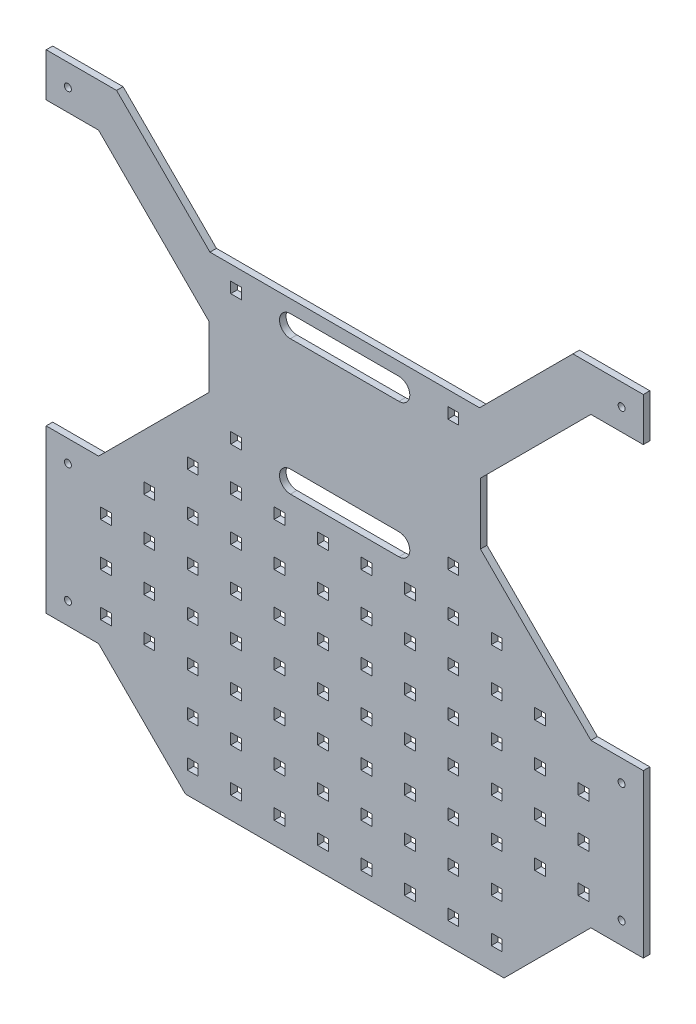
from build123d import *

# Parameters (mm, degrees)
EXTRUDE1_DEPTH     = 3
CUT_EXTRUDE2_DEPTH = 3
EXTRUDE3_DEPTH     = 10
SKETCH6_R          = 1.6
EXTRUDE4_DEPTH     = 50
SKETCH7_W          = 5
SKETCH7_H          = 5
EXTRUDE5_DEPTH     = 50


with BuildPart() as part:
    # Sketch1 → Extrude1 (new body)
    with BuildSketch(Plane.XY):
        Polygon((-21.510078765, 357.497048214), (2.632056859, 357.497048214), (53.489921235, 306.639183837), (53.489921235, 278.35491259), (2.632056859, 227.497048214), (-21.510078765, 227.497048214), (-21.510078765, 152.709593142), (2.632056859, 152.709593142), (42.632056859, 112.709593142), (189.347785611, 112.709593142), (229.347785611, 152.709593142), (253.489921235, 152.709593142), (253.489921235, 227.497048214), (229.347785611, 227.497048214), (178.489921235, 278.35491259), (178.489921235, 306.639183837), (229.347785611, 357.497048214), (253.489921235, 357.497048214), (253.489921235, 432.284503285), (185.989921235, 432.284503285), (165.989921235, 412.284503285), (65.989921235, 412.284503285), (45.989921235, 432.284503285), (-21.510078765, 432.284503285), align=None)
    extrude(amount=EXTRUDE1_DEPTH)

    # Sketch3 → Cut-Extrude2 (cut)
    with BuildSketch(Plane.XY.offset(3)):
        with BuildLine():
            Line((90.948770211, 328.497048214), (140.948770211, 328.497048214))
            ThreePointArc((140.948770211, 328.497048214), (145.948770211, 323.497048214), (140.948770211, 318.497048214))
            Line((140.948770211, 318.497048214), (90.948770211, 318.497048214))
            ThreePointArc((90.948770211, 318.497048214), (85.948770211, 323.497048214), (90.948770211, 328.497048214))
        make_face()
        with BuildLine():
            Line((90.948770211, 256.497048214), (140.948770211, 256.497048214))
            ThreePointArc((140.948770211, 256.497048214), (145.948770211, 261.497048214), (140.948770211, 266.497048214))
            Line((140.948770211, 266.497048214), (90.948770211, 266.497048214))
            ThreePointArc((90.948770211, 266.497048214), (85.948770211, 261.497048214), (90.948770211, 256.497048214))
        make_face()
    extrude(amount=-CUT_EXTRUDE2_DEPTH, mode=Mode.SUBTRACT)

    # Sketch5 → Extrude3 (cut)
    with BuildSketch(Plane(origin=(0, 0, 0), x_dir=(-1, 0, 0), z_dir=(0, 0, -1))):
        Polygon((-253.489921235, 377.497048214), (-221.063514364, 377.497048214), (-178.063514364, 334.497048214), (-53.916328106, 334.497048214), (-10.916328106, 377.497048214), (21.510078765, 377.497048214), (21.510078765, 432.284503285), (-253.489921235, 432.284503285), align=None)
    extrude(amount=-EXTRUDE3_DEPTH, mode=Mode.SUBTRACT)

    # Sketch6 → Extrude4 (cut)
    with BuildSketch(Plane.XY.offset(3)):
        with Locations((-11.510078765, 367.497048214)):
            Circle(SKETCH6_R)
        with Locations((-11.510078765, 217.497048214)):
            Circle(SKETCH6_R)
        with Locations((-11.510078765, 162.709593142)):
            Circle(SKETCH6_R)
        with Locations((243.489921235, 162.709593142)):
            Circle(SKETCH6_R)
        with Locations((243.489921235, 217.497048214)):
            Circle(SKETCH6_R)
        with Locations((243.489921235, 367.497048214)):
            Circle(SKETCH6_R)
    extrude(amount=-EXTRUDE4_DEPTH, mode=Mode.SUBTRACT)

    # Sketch7 → Extrude5 (cut)
    with BuildSketch(Plane.XY.offset(3)):
        with Locations((45.989921235, 125.209593142)):
            Rectangle(SKETCH7_W, SKETCH7_H)
        with Locations((65.989921235, 125.209593142)):
            Rectangle(SKETCH7_W, SKETCH7_H)
        with Locations((85.989921235, 125.209593142)):
            Rectangle(SKETCH7_W, SKETCH7_H)
        with Locations((105.989921235, 125.209593142)):
            Rectangle(SKETCH7_W, SKETCH7_H)
        with Locations((125.989921235, 125.209593142)):
            Rectangle(SKETCH7_W, SKETCH7_H)
        with Locations((145.989921235, 125.209593142)):
            Rectangle(SKETCH7_W, SKETCH7_H)
        with Locations((165.989921235, 125.209593142)):
            Rectangle(SKETCH7_W, SKETCH7_H)
        with Locations((185.989921235, 125.209593142)):
            Rectangle(SKETCH7_W, SKETCH7_H)
        with Locations((45.989921235, 145.209593142)):
            Rectangle(SKETCH7_W, SKETCH7_H)
        with Locations((65.989921235, 145.209593142)):
            Rectangle(SKETCH7_W, SKETCH7_H)
        with Locations((85.989921235, 145.209593142)):
            Rectangle(SKETCH7_W, SKETCH7_H)
        with Locations((105.989921235, 145.209593142)):
            Rectangle(SKETCH7_W, SKETCH7_H)
        with Locations((125.989921235, 145.209593142)):
            Rectangle(SKETCH7_W, SKETCH7_H)
        with Locations((145.989921235, 145.209593142)):
            Rectangle(SKETCH7_W, SKETCH7_H)
        with Locations((165.989921235, 145.209593142)):
            Rectangle(SKETCH7_W, SKETCH7_H)
        with Locations((185.989921235, 145.209593142)):
            Rectangle(SKETCH7_W, SKETCH7_H)
        with Locations((25.989921235, 165.209593142)):
            Rectangle(SKETCH7_W, SKETCH7_H)
        with Locations((45.989921235, 165.209593142)):
            Rectangle(SKETCH7_W, SKETCH7_H)
        with Locations((65.989921235, 165.209593142)):
            Rectangle(SKETCH7_W, SKETCH7_H)
        with Locations((85.989921235, 165.209593142)):
            Rectangle(SKETCH7_W, SKETCH7_H)
        with Locations((105.989921235, 165.209593142)):
            Rectangle(SKETCH7_W, SKETCH7_H)
        with Locations((125.989921235, 165.209593142)):
            Rectangle(SKETCH7_W, SKETCH7_H)
        with Locations((145.989921235, 165.209593142)):
            Rectangle(SKETCH7_W, SKETCH7_H)
        with Locations((165.989921235, 165.209593142)):
            Rectangle(SKETCH7_W, SKETCH7_H)
        with Locations((185.989921235, 165.209593142)):
            Rectangle(SKETCH7_W, SKETCH7_H)
        with Locations((205.989921235, 165.209593142)):
            Rectangle(SKETCH7_W, SKETCH7_H)
        with Locations((225.989921235, 165.209593142)):
            Rectangle(SKETCH7_W, SKETCH7_H)
        with Locations((25.989921235, 185.209593142)):
            Rectangle(SKETCH7_W, SKETCH7_H)
        with Locations((45.989921235, 185.209593142)):
            Rectangle(SKETCH7_W, SKETCH7_H)
        with Locations((65.989921235, 185.209593142)):
            Rectangle(SKETCH7_W, SKETCH7_H)
        with Locations((85.989921235, 185.209593142)):
            Rectangle(SKETCH7_W, SKETCH7_H)
        with Locations((105.989921235, 185.209593142)):
            Rectangle(SKETCH7_W, SKETCH7_H)
        with Locations((125.989921235, 185.209593142)):
            Rectangle(SKETCH7_W, SKETCH7_H)
        with Locations((145.989921235, 185.209593142)):
            Rectangle(SKETCH7_W, SKETCH7_H)
        with Locations((165.989921235, 185.209593142)):
            Rectangle(SKETCH7_W, SKETCH7_H)
        with Locations((185.989921235, 185.209593142)):
            Rectangle(SKETCH7_W, SKETCH7_H)
        with Locations((205.989921235, 185.209593142)):
            Rectangle(SKETCH7_W, SKETCH7_H)
        with Locations((225.989921235, 185.209593142)):
            Rectangle(SKETCH7_W, SKETCH7_H)
        with Locations((25.989921235, 205.209593142)):
            Rectangle(SKETCH7_W, SKETCH7_H)
        with Locations((45.989921235, 205.209593142)):
            Rectangle(SKETCH7_W, SKETCH7_H)
        with Locations((65.989921235, 205.209593142)):
            Rectangle(SKETCH7_W, SKETCH7_H)
        with Locations((85.989921235, 205.209593142)):
            Rectangle(SKETCH7_W, SKETCH7_H)
        with Locations((105.989921235, 205.209593142)):
            Rectangle(SKETCH7_W, SKETCH7_H)
        with Locations((125.989921235, 205.209593142)):
            Rectangle(SKETCH7_W, SKETCH7_H)
        with Locations((145.989921235, 205.209593142)):
            Rectangle(SKETCH7_W, SKETCH7_H)
        with Locations((165.989921235, 205.209593142)):
            Rectangle(SKETCH7_W, SKETCH7_H)
        with Locations((185.989921235, 205.209593142)):
            Rectangle(SKETCH7_W, SKETCH7_H)
        with Locations((205.989921235, 205.209593142)):
            Rectangle(SKETCH7_W, SKETCH7_H)
        with Locations((225.989921235, 205.209593142)):
            Rectangle(SKETCH7_W, SKETCH7_H)
        with Locations((25.989921235, 225.209593142)):
            Rectangle(SKETCH7_W, SKETCH7_H)
        with Locations((45.989921235, 225.209593142)):
            Rectangle(SKETCH7_W, SKETCH7_H)
        with Locations((65.989921235, 225.209593142)):
            Rectangle(SKETCH7_W, SKETCH7_H)
        with Locations((85.989921235, 225.209593142)):
            Rectangle(SKETCH7_W, SKETCH7_H)
        with Locations((105.989921235, 225.209593142)):
            Rectangle(SKETCH7_W, SKETCH7_H)
        with Locations((125.989921235, 225.209593142)):
            Rectangle(SKETCH7_W, SKETCH7_H)
        with Locations((145.989921235, 225.209593142)):
            Rectangle(SKETCH7_W, SKETCH7_H)
        with Locations((165.989921235, 225.209593142)):
            Rectangle(SKETCH7_W, SKETCH7_H)
        with Locations((185.989921235, 225.209593142)):
            Rectangle(SKETCH7_W, SKETCH7_H)
        with Locations((205.989921235, 225.209593142)):
            Rectangle(SKETCH7_W, SKETCH7_H)
        with Locations((45.989921235, 245.209593142)):
            Rectangle(SKETCH7_W, SKETCH7_H)
        with Locations((65.989921235, 245.209593142)):
            Rectangle(SKETCH7_W, SKETCH7_H)
        with Locations((85.989921235, 245.209593142)):
            Rectangle(SKETCH7_W, SKETCH7_H)
        with Locations((105.989921235, 245.209593142)):
            Rectangle(SKETCH7_W, SKETCH7_H)
        with Locations((125.989921235, 245.209593142)):
            Rectangle(SKETCH7_W, SKETCH7_H)
        with Locations((145.989921235, 245.209593142)):
            Rectangle(SKETCH7_W, SKETCH7_H)
        with Locations((165.989921235, 245.209593142)):
            Rectangle(SKETCH7_W, SKETCH7_H)
        with Locations((185.989921235, 245.209593142)):
            Rectangle(SKETCH7_W, SKETCH7_H)
        with Locations((65.989921235, 265.209593142)):
            Rectangle(SKETCH7_W, SKETCH7_H)
        with Locations((165.989921235, 265.209593142)):
            Rectangle(SKETCH7_W, SKETCH7_H)
        with Locations((65.989921235, 325.209593142)):
            Rectangle(SKETCH7_W, SKETCH7_H)
        with Locations((165.989921235, 325.209593142)):
            Rectangle(SKETCH7_W, SKETCH7_H)
        with Locations((5.989921235, 165.209593142)):
            Rectangle(SKETCH7_W, SKETCH7_H)
        with Locations((5.989921235, 185.209593142)):
            Rectangle(SKETCH7_W, SKETCH7_H)
        with Locations((5.989921235, 205.209593142)):
            Rectangle(SKETCH7_W, SKETCH7_H)
    extrude(amount=-EXTRUDE5_DEPTH, mode=Mode.SUBTRACT)


solid = part.part
